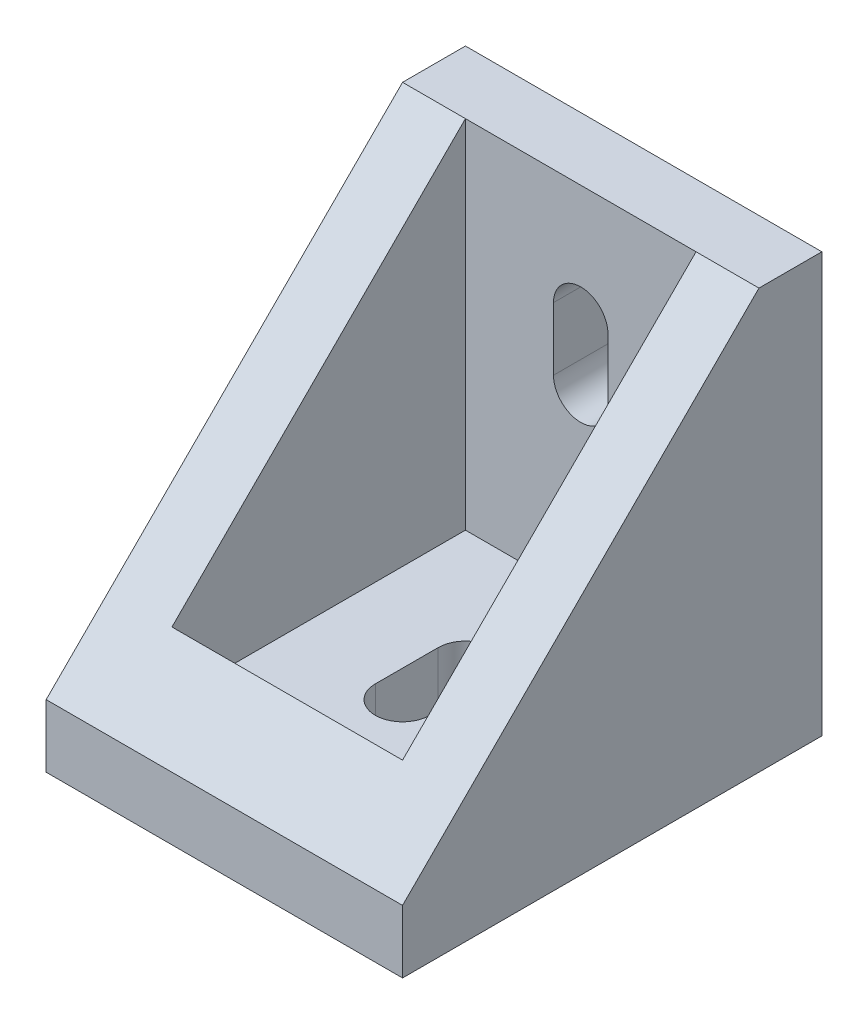
from build123d import *

# Parameters (mm, degrees)
SKETCH1_W           = 17
SKETCH1_H           = 20
BOSS_EXTRUDE1_DEPTH = 20
SHELL1_T            = -3
CUT_EXTRUDE1_DEPTH  = 18
CUT_EXTRUDE2_DEPTH  = 4
CUT_EXTRUDE3_DEPTH  = 4


with BuildPart() as part:
    # Sketch1 → Boss-Extrude1 (new body)
    with BuildSketch(Plane(origin=(0, 0, 0), x_dir=(1, 0, 0), z_dir=(0, 1, 0))):
        Rectangle(SKETCH1_W, SKETCH1_H)
    extrude(amount=BOSS_EXTRUDE1_DEPTH)

    # Shell1
    shell1_openings = [part.faces().sort_by_distance(p)[0] for p in [
        (0, 20, 0),
    ]]
    offset(amount=SHELL1_T, openings=shell1_openings, kind=Kind.INTERSECTION)

    # Sketch3 → Cut-Extrude1 (cut, through all)
    with BuildSketch(Plane(origin=(8.5, 0, 0), x_dir=(0, 0, -1), z_dir=(1, 0, 0))):
        Polygon((7, 20), (-10, 20), (-10, 3), align=None)
    extrude(amount=-CUT_EXTRUDE1_DEPTH, mode=Mode.SUBTRACT)

    # Sketch4 → Cut-Extrude2 (cut, through all)
    with BuildSketch(Plane(origin=(0, 3, 0), x_dir=(1, 0, 0), z_dir=(0, 1, 0))):
        with BuildLine():
            Line((1.3, 1.5), (1.3, -1.5))
            ThreePointArc((1.3, -1.5), (0, -2.8), (-1.3, -1.5))
            Line((-1.3, -1.5), (-1.3, 1.5))
            ThreePointArc((-1.3, 1.5), (0, 2.8), (1.3, 1.5))
        make_face()
    extrude(amount=-CUT_EXTRUDE2_DEPTH, mode=Mode.SUBTRACT)

    # Sketch5 → Cut-Extrude3 (cut, through all)
    with BuildSketch(Plane.XY.offset(-7)):
        with BuildLine():
            Line((1.3, 14.5), (1.3, 11.5))
            ThreePointArc((1.3, 11.5), (0, 10.2), (-1.3, 11.5))
            Line((-1.3, 11.5), (-1.3, 14.5))
            ThreePointArc((-1.3, 14.5), (0, 15.8), (1.3, 14.5))
        make_face()
    extrude(amount=-CUT_EXTRUDE3_DEPTH, mode=Mode.SUBTRACT)


solid = part.part
